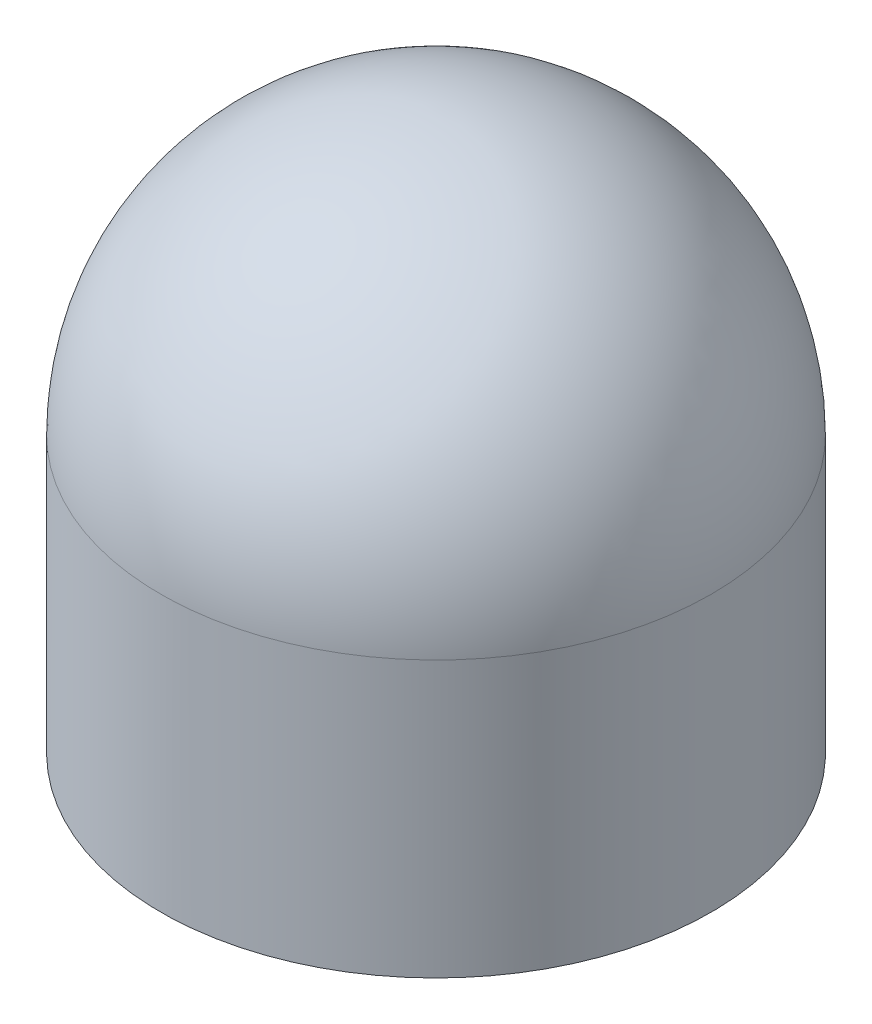
from build123d import *


with BuildPart() as part:
    # Sketch1 → Revolve1 (revolve)
    with BuildSketch(Plane.XY):
        with BuildLine():
            Line((0, 0), (30, 0))
            Line((30, 0), (30, 30))
            ThreePointArc((30, 30), (21.213203436, 51.213203436), (0, 60))
            Line((0, 60), (0, 0))
        make_face()
    revolve(axis=Axis((0, 0, 0), (0, 1, 0)))


solid = part.part
